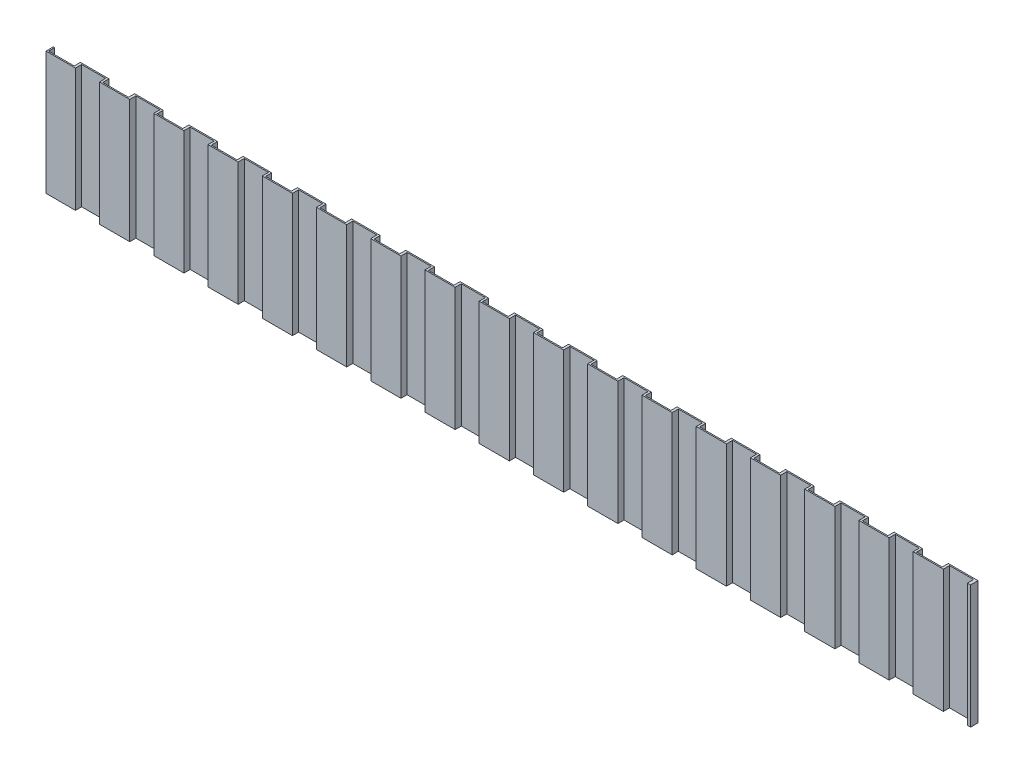
from build123d import *

# Parameters (mm, degrees)
SKETCH1_W           = 7500
SKETCH1_H           = 4000
BOSS_EXTRUDE1_DEPTH = 60
SKETCH2_W           = 208.04993412
SKETCH2_H           = 50
SKETCH2_W_2         = 195.302892205
CUT_EXTRUDE1_DEPTH  = 5107
SKETCH3_W           = 8196.868920553
SKETCH3_H           = 2618.215118215
CUT_EXTRUDE2_DEPTH  = 1189.715985199
SKETCH4_W           = 8610.420371691
SKETCH4_H           = 2020.754263889
CUT_EXTRUDE3_DEPTH  = 1189.715985199


with BuildPart() as part:
    # Sketch1 → Boss-Extrude1 (new body)
    with BuildSketch(Plane.XY):
        Rectangle(SKETCH1_W, SKETCH1_H)
    extrude(amount=BOSS_EXTRUDE1_DEPTH)

    # Sketch2 → Cut-Extrude1 (cut)
    with BuildSketch(Plane(origin=(0, -2000, 0), x_dir=(-1, 0, 0), z_dir=(0, -1, 0))):
        with Locations((3635.051095731, -25)):
            Rectangle(SKETCH2_W, SKETCH2_H)
        with Locations((3413.343616701, -35)):
            Rectangle(SKETCH2_W_2, SKETCH2_H)
        with Locations((3195.051095731, -25)):
            Rectangle(SKETCH2_W, SKETCH2_H)
        with Locations((2973.343616701, -35)):
            Rectangle(SKETCH2_W_2, SKETCH2_H)
        with Locations((2755.051095731, -25)):
            Rectangle(SKETCH2_W, SKETCH2_H)
        with Locations((2533.343616701, -35)):
            Rectangle(SKETCH2_W_2, SKETCH2_H)
        with Locations((2315.051095731, -25)):
            Rectangle(SKETCH2_W, SKETCH2_H)
        with Locations((2093.343616701, -35)):
            Rectangle(SKETCH2_W_2, SKETCH2_H)
        with Locations((1875.051095731, -25)):
            Rectangle(SKETCH2_W, SKETCH2_H)
        with Locations((1653.343616701, -35)):
            Rectangle(SKETCH2_W_2, SKETCH2_H)
        with Locations((1435.051095731, -25)):
            Rectangle(SKETCH2_W, SKETCH2_H)
        with Locations((1213.343616701, -35)):
            Rectangle(SKETCH2_W_2, SKETCH2_H)
        with Locations((995.051095731, -25)):
            Rectangle(SKETCH2_W, SKETCH2_H)
        with Locations((773.343616701, -35)):
            Rectangle(SKETCH2_W_2, SKETCH2_H)
        with Locations((555.051095731, -25)):
            Rectangle(SKETCH2_W, SKETCH2_H)
        with Locations((333.343616701, -35)):
            Rectangle(SKETCH2_W_2, SKETCH2_H)
        with Locations((115.051095731, -25)):
            Rectangle(SKETCH2_W, SKETCH2_H)
        with Locations((-106.6563833, -35)):
            Rectangle(SKETCH2_W_2, SKETCH2_H)
        with Locations((-324.948904269, -25)):
            Rectangle(SKETCH2_W, SKETCH2_H)
        with Locations((-546.6563833, -35)):
            Rectangle(SKETCH2_W_2, SKETCH2_H)
        with Locations((-764.948904269, -25)):
            Rectangle(SKETCH2_W, SKETCH2_H)
        with Locations((-986.6563833, -35)):
            Rectangle(SKETCH2_W_2, SKETCH2_H)
        with Locations((-1204.948904269, -25)):
            Rectangle(SKETCH2_W, SKETCH2_H)
        with Locations((-1426.6563833, -35)):
            Rectangle(SKETCH2_W_2, SKETCH2_H)
        with Locations((-1644.948904269, -25)):
            Rectangle(SKETCH2_W, SKETCH2_H)
        with Locations((-1866.6563833, -35)):
            Rectangle(SKETCH2_W_2, SKETCH2_H)
        with Locations((-2084.948904269, -25)):
            Rectangle(SKETCH2_W, SKETCH2_H)
        with Locations((-2306.6563833, -35)):
            Rectangle(SKETCH2_W_2, SKETCH2_H)
        with Locations((-2524.948904269, -25)):
            Rectangle(SKETCH2_W, SKETCH2_H)
        with Locations((-2746.6563833, -35)):
            Rectangle(SKETCH2_W_2, SKETCH2_H)
        with Locations((-2964.948904269, -25)):
            Rectangle(SKETCH2_W, SKETCH2_H)
        with Locations((-3186.6563833, -35)):
            Rectangle(SKETCH2_W_2, SKETCH2_H)
        with Locations((-3404.948904269, -25)):
            Rectangle(SKETCH2_W, SKETCH2_H)
        with Locations((-3626.6563833, -35)):
            Rectangle(SKETCH2_W_2, SKETCH2_H)
    extrude(amount=-CUT_EXTRUDE1_DEPTH, mode=Mode.SUBTRACT)

    # Sketch3 → Cut-Extrude2 (cut)
    with BuildSketch(Plane.XY.offset(60)):
        with Locations((348.434460276, -1309.107559108)):
            Rectangle(SKETCH3_W, SKETCH3_H)
    extrude(amount=-CUT_EXTRUDE2_DEPTH, mode=Mode.SUBTRACT)

    # Sketch4 → Cut-Extrude3 (cut)
    with BuildSketch(Plane.XY.offset(60)):
        with Locations((555.210185846, -10.377131944)):
            Rectangle(SKETCH4_W, SKETCH4_H)
    extrude(amount=-CUT_EXTRUDE3_DEPTH, mode=Mode.SUBTRACT)


solid = part.part
